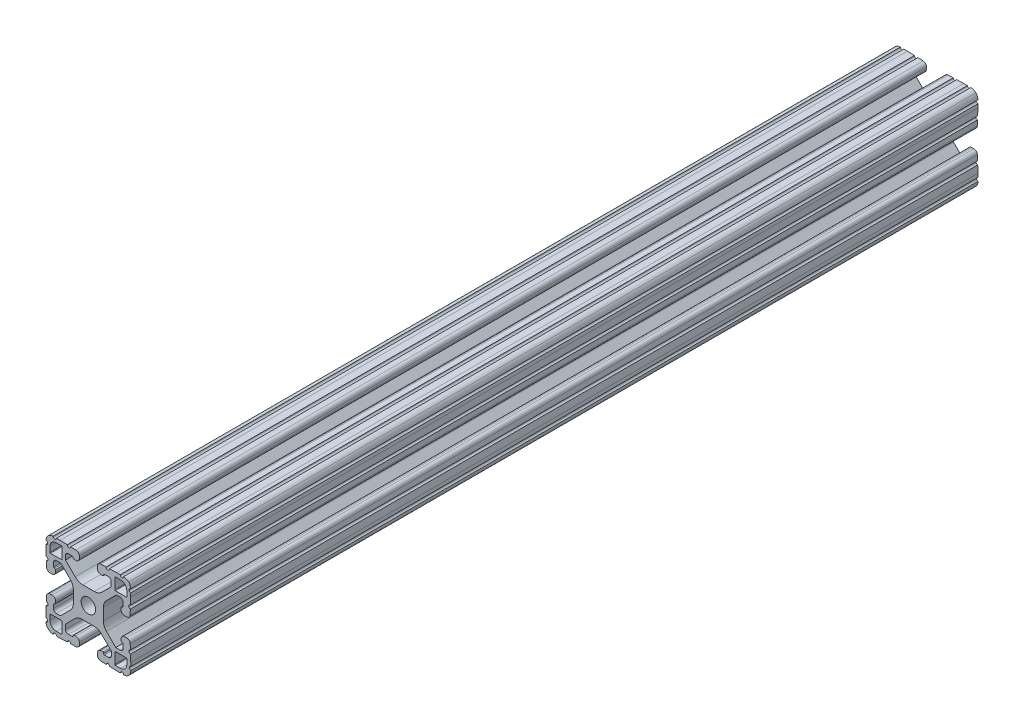
from build123d import *

# Parameters (mm, degrees)
SKETCH1_R           = 3.2639
BOSS_EXTRUDE1_DEPTH = 381


with BuildPart() as part:
    # Sketch1 → Boss-Extrude1 (new body)
    with BuildSketch(Plane(origin=(0, 0, -25.4), x_dir=(-1, 0, 0), z_dir=(0, 0, -1))):
        with BuildLine():
            Line((-88.043721549, 91.862643967), (-86.29674679, 91.923648859))
            ThreePointArc((-86.29674679, 91.923648859), (-85.370208675, 91.567983831), (-84.982425017, 90.654422489))
            Line((-84.982425017, 90.654422489), (-84.982425017, 88.800173916))
            Line((-84.982425017, 88.800173916), (-89.306565884, 84.476033049))
            ThreePointArc((-89.306565884, 84.476033049), (-90.866149908, 83.406077005), (-92.719610366, 83.029523439))
            Line((-92.719610366, 83.029523439), (-97.961628589, 83.029523439))
            ThreePointArc((-97.961628589, 83.029523439), (-99.779298356, 83.391080435), (-101.320244378, 84.42070765))
            Line((-101.320244378, 84.42070765), (-105.516001761, 88.616465033))
            Line((-105.516001761, 88.616465033), (-105.516001761, 90.731330035))
            ThreePointArc((-105.516001761, 90.731330035), (-105.128218103, 91.644891377), (-104.201679988, 92.000556406))
            Line((-104.201679988, 92.000556406), (-102.454705229, 91.939551513))
            ThreePointArc((-102.454705229, 91.939551513), (-102.193933359, 91.823448504), (-102.087001761, 91.558783602))
            ThreePointArc((-102.087001761, 91.558783602), (-102.010859042, 91.249291513), (-101.726191901, 91.105946874))
            Line((-101.726191901, 91.105946874), (-100.929727576, 91.078102142))
            ThreePointArc((-100.929727576, 91.078102142), (-99.780779944, 91.519102656), (-99.299905511, 92.651940638))
            Line((-99.299905511, 92.651940638), (-99.299905511, 93.566848638))
            ThreePointArc((-99.299905511, 93.566848638), (-99.741889517, 94.660796975), (-100.819746715, 95.140689345))
            Line((-100.819746715, 95.140689345), (-103.211918901, 95.224224422))
            ThreePointArc((-103.211918901, 95.224224422), (-104.000045777, 94.489281495), (-104.734990687, 95.277406522))
            Line((-104.734990687, 95.277406522), (-107.935905676, 95.389166912))
            Line((-107.935905676, 95.389166912), (-109.561454876, 95.389166912))
            ThreePointArc((-109.561454876, 95.389166912), (-110.323454876, 94.627166912), (-111.085454876, 95.389166912))
            ThreePointArc((-111.085454876, 95.389166912), (-112.308767787, 95.144035599), (-113.343184761, 94.446493225))
            ThreePointArc((-113.343184761, 94.446493225), (-114.04072548, 93.412075135), (-114.285854836, 92.188761832))
            ThreePointArc((-114.285854836, 92.188761832), (-113.523853616, 91.426762441), (-114.285853616, 90.664761832))
            Line((-114.285853616, 90.664761832), (-114.285853616, 89.039212632))
            Line((-114.285853616, 89.039212632), (-114.174093219, 85.838297643))
            ThreePointArc((-114.174093219, 85.838297643), (-113.385968191, 85.103352735), (-114.120911115, 84.315225857))
            Line((-114.120911115, 84.315225857), (-114.037376031, 81.923053667))
            ThreePointArc((-114.037376031, 81.923053667), (-113.55748366, 80.845196472), (-112.463535325, 80.403212468))
            Line((-112.463535325, 80.403212468), (-111.548627325, 80.403212468))
            ThreePointArc((-111.548627325, 80.403212468), (-110.415788905, 80.884087354), (-109.974788872, 82.033035791))
            Line((-109.974788872, 82.033035791), (-110.002634241, 82.829500094))
            ThreePointArc((-110.002634241, 82.829500094), (-110.118742417, 83.090261917), (-110.383401914, 83.197188))
            ThreePointArc((-110.383401914, 83.197188), (-110.693757401, 83.272605688), (-110.837665276, 83.557735272))
            Line((-110.837665276, 83.557735272), (-110.898671566, 85.304709982))
            ThreePointArc((-110.898671566, 85.304709982), (-110.543006925, 86.231248747), (-109.62944523, 86.61903277))
            Line((-109.62944523, 86.61903277), (-107.807161806, 86.61903277))
            Line((-107.807161806, 86.61903277), (-103.364925613, 82.176810793))
            ThreePointArc((-103.364925613, 82.176810793), (-102.335294479, 80.635862907), (-101.973736029, 78.81818963))
            Line((-101.973736029, 78.81818963), (-101.973736029, 73.576034207))
            ThreePointArc((-101.973736029, 73.576034207), (-102.335293752, 71.758362684), (-103.364922926, 70.21741573))
            Line((-103.364922926, 70.21741573), (-107.560683666, 66.021661704))
            Line((-107.560683666, 66.021661704), (-109.652436558, 66.021661704))
            ThreePointArc((-109.652436558, 66.021661704), (-110.565998503, 66.409445617), (-110.921663765, 67.335984343))
            Line((-110.921663765, 67.335984343), (-110.860658873, 69.082959102))
            ThreePointArc((-110.860658873, 69.082959102), (-110.744555864, 69.343730973), (-110.479890961, 69.45066257))
            ThreePointArc((-110.479890961, 69.45066257), (-110.173494703, 69.529390272), (-110.032185196, 69.812424443))
            Line((-110.032185196, 69.812424443), (-110.004340464, 70.608888768))
            ThreePointArc((-110.004340464, 70.608888768), (-110.445340978, 71.7578364), (-111.57817896, 72.238710833))
            Line((-111.57817896, 72.238710833), (-112.49308696, 72.238710833))
            ThreePointArc((-112.49308696, 72.238710833), (-113.587035297, 71.796726827), (-114.066927667, 70.718869629))
            Line((-114.066927667, 70.718869629), (-114.150462744, 68.326697443))
            ThreePointArc((-114.150462744, 68.326697443), (-113.415519817, 67.538570567), (-114.203644843, 66.803625657))
            Line((-114.203644843, 66.803625657), (-114.315405233, 63.602710668))
            Line((-114.315405233, 63.602710668), (-114.315405233, 61.962557497))
            ThreePointArc((-114.315405233, 61.962557497), (-113.701927281, 61.206106537), (-114.333208228, 60.464447842))
            ThreePointArc((-114.333208228, 60.464447842), (-114.113020459, 59.176546471), (-113.392816136, 58.086372941))
            ThreePointArc((-113.392816136, 58.086372941), (-112.358398046, 57.388832223), (-111.135084743, 57.143702867))
            ThreePointArc((-111.135084743, 57.143702867), (-110.373085352, 57.905704086), (-109.611084743, 57.143704086))
            Line((-109.611084743, 57.143704086), (-107.985535543, 57.143704086))
            Line((-107.985535543, 57.143704086), (-104.784620554, 57.255464483))
            ThreePointArc((-104.784620554, 57.255464483), (-104.049675645, 58.04358951), (-103.261548768, 57.308646586))
            Line((-103.261548768, 57.308646586), (-100.869376578, 57.39218167))
            ThreePointArc((-100.869376578, 57.39218167), (-99.791519383, 57.872074041), (-99.349535378, 58.966022376))
            Line((-99.349535378, 58.966022376), (-99.349535378, 59.880930376))
            ThreePointArc((-99.349535378, 59.880930376), (-99.830409811, 61.013768358), (-100.979357443, 61.454768873))
            Line((-100.979357443, 61.454768873), (-101.775821768, 61.42692414))
            ThreePointArc((-101.775821768, 61.42692414), (-102.036583684, 61.310816174), (-102.143509978, 61.046156762))
            ThreePointArc((-102.143509978, 61.046156762), (-102.222494916, 60.740061862), (-102.505377386, 60.598958297))
            Line((-102.505377386, 60.598958297), (-104.252352145, 60.537953405))
            ThreePointArc((-104.252352145, 60.537953405), (-105.17889026, 60.893618433), (-105.566673918, 61.807179775))
            Line((-105.566673918, 61.807179775), (-105.566673918, 63.629462758))
            Line((-105.566673918, 63.629462758), (-101.131142468, 68.064994208))
            ThreePointArc((-101.131142468, 68.064994208), (-99.590196446, 69.094621422), (-97.772526678, 69.456178419))
            Line((-97.772526678, 69.456178419), (-92.530356056, 69.456178419))
            ThreePointArc((-92.530356056, 69.456178419), (-90.712686289, 69.094621422), (-89.171740267, 68.064994208))
            Line((-89.171740267, 68.064994208), (-84.975982884, 63.869236825))
            Line((-84.975982884, 63.869236825), (-84.975982884, 61.781050107))
            ThreePointArc((-84.975982884, 61.781050107), (-85.363766542, 60.867488765), (-86.290304657, 60.511823736))
            Line((-86.290304657, 60.511823736), (-88.037279416, 60.572828629))
            ThreePointArc((-88.037279416, 60.572828629), (-88.298051286, 60.688931638), (-88.404982884, 60.95359654))
            ThreePointArc((-88.404982884, 60.95359654), (-88.466593694, 61.278962759), (-88.759626911, 61.433204782))
            Line((-88.759626911, 61.433204782), (-89.556091237, 61.461049514))
            ThreePointArc((-89.556091237, 61.461049514), (-90.705038868, 61.020049), (-91.185913301, 59.887211018))
            Line((-91.185913301, 59.887211018), (-91.185913301, 58.972303018))
            ThreePointArc((-91.185913301, 58.972303018), (-90.743929295, 57.878354681), (-89.666072098, 57.398462311))
            Line((-89.666072098, 57.398462311), (-87.273899911, 57.314927234))
            ThreePointArc((-87.273899911, 57.314927234), (-86.485773036, 58.049870161), (-85.750828126, 57.261745135))
            Line((-85.750828126, 57.261745135), (-82.549913136, 57.149984745))
            Line((-82.549913136, 57.149984745), (-80.924363936, 57.149984745))
            ThreePointArc((-80.924363936, 57.149984745), (-80.162363936, 57.911984745), (-79.400363936, 57.149984745))
            ThreePointArc((-79.400363936, 57.149984745), (-78.177051025, 57.395116058), (-77.142634052, 58.092658432))
            ThreePointArc((-77.142634052, 58.092658432), (-76.445094372, 59.127074031), (-76.199963977, 60.350384428))
            ThreePointArc((-76.199963977, 60.350384428), (-76.961961268, 61.112385783), (-76.199961268, 61.874384428))
            Line((-76.199961268, 61.874384428), (-76.199961268, 63.499933628))
            Line((-76.199961268, 63.499933628), (-76.311721666, 66.700848617))
            ThreePointArc((-76.311721666, 66.700848617), (-77.099846694, 67.435793525), (-76.364903769, 68.223920403))
            Line((-76.364903769, 68.223920403), (-76.448438853, 70.616092593))
            ThreePointArc((-76.448438853, 70.616092593), (-76.928331225, 71.693949788), (-78.02227956, 72.135933792))
            Line((-78.02227956, 72.135933792), (-78.93718756, 72.135933792))
            ThreePointArc((-78.93718756, 72.135933792), (-80.07002598, 71.655058906), (-80.511026012, 70.506110469))
            Line((-80.511026012, 70.506110469), (-80.483180643, 69.709646166))
            ThreePointArc((-80.483180643, 69.709646166), (-80.367072468, 69.448884343), (-80.102412971, 69.34195826))
            ThreePointArc((-80.102412971, 69.34195826), (-79.796317908, 69.262973649), (-79.655214052, 68.980091239))
            Line((-79.655214052, 68.980091239), (-79.594207761, 67.233116529))
            ThreePointArc((-79.594207761, 67.233116529), (-79.949872402, 66.306577764), (-80.863434097, 65.918793741))
            Line((-80.863434097, 65.918793741), (-82.685717521, 65.918793741))
            Line((-82.685717521, 65.918793741), (-87.121258001, 70.35431293))
            ThreePointArc((-87.121258001, 70.35431293), (-88.150863946, 71.895196205), (-88.512450271, 73.712794894))
            Line((-88.512450271, 73.712794894), (-88.512606864, 78.954950317))
            ThreePointArc((-88.512606864, 78.954950317), (-88.151076291, 80.772698182), (-87.121419968, 82.313710679))
            Line((-87.121419968, 82.313710679), (-82.925659228, 86.509464706))
            Line((-82.925659228, 86.509464706), (-80.837473527, 86.509464706))
            ThreePointArc((-80.837473527, 86.509464706), (-79.923911584, 86.121680793), (-79.568246321, 85.195142068))
            Line((-79.568246321, 85.195142068), (-79.629251214, 83.448167309))
            ThreePointArc((-79.629251214, 83.448167309), (-79.745354223, 83.187395438), (-80.010019125, 83.080463841))
            ThreePointArc((-80.010019125, 83.080463841), (-80.335385344, 83.018853031), (-80.489627367, 82.725819813))
            Line((-80.489627367, 82.725819813), (-80.5174721, 81.929355488))
            ThreePointArc((-80.5174721, 81.929355488), (-80.076471586, 80.780407856), (-78.943633603, 80.299533423))
            Line((-78.943633603, 80.299533423), (-78.028725603, 80.299533423))
            ThreePointArc((-78.028725603, 80.299533423), (-76.934777267, 80.741517429), (-76.454884897, 81.819374627))
            Line((-76.454884897, 81.819374627), (-76.37134982, 84.211546813))
            ThreePointArc((-76.37134982, 84.211546813), (-77.106292747, 84.999673689), (-76.31816772, 85.734618599))
            Line((-76.31816772, 85.734618599), (-76.20640733, 88.935533588))
            Line((-76.20640733, 88.935533588), (-76.20640733, 90.561082788))
            ThreePointArc((-76.20640733, 90.561082788), (-76.96840733, 91.323083398), (-76.206406111, 92.085082788))
            ThreePointArc((-76.206406111, 92.085082788), (-76.451535467, 93.308396091), (-77.149076185, 94.342814181))
            ThreePointArc((-77.149076185, 94.342814181), (-78.183493159, 95.040356555), (-79.40680607, 95.285487868))
            ThreePointArc((-79.40680607, 95.285487868), (-80.16880607, 94.523487868), (-80.93080607, 95.285487868))
            Line((-80.93080607, 95.285487868), (-82.55635527, 95.285487868))
            Line((-82.55635527, 95.285487868), (-85.757270259, 95.173727471))
            ThreePointArc((-85.757270259, 95.173727471), (-86.492215168, 94.385602444), (-87.280342045, 95.120545368))
            Line((-87.280342045, 95.120545368), (-89.672514235, 95.037010285))
            ThreePointArc((-89.672514235, 95.037010285), (-90.75037143, 94.557117913), (-91.192355435, 93.463169578))
            Line((-91.192355435, 93.463169578), (-91.192355435, 92.548261578))
            ThreePointArc((-91.192355435, 92.548261578), (-90.711481002, 91.415423596), (-89.56253337, 90.974423082))
            Line((-89.56253337, 90.974423082), (-88.766069045, 91.002267814))
            ThreePointArc((-88.766069045, 91.002267814), (-88.505307129, 91.11837578), (-88.398380835, 91.383035192))
            ThreePointArc((-88.398380835, 91.383035192), (-88.336765486, 91.708407548), (-88.043721549, 91.862643967))
        make_face()
        with Locations(Location((-95.25, 76.2, 0), (0, 0, 180))):  # turned: the seam where the file's is
            Circle(SKETCH1_R, mode=Mode.SUBTRACT)
        with BuildLine():
            Line((-83.357745393, 88.294108398), (-83.357745393, 93.170908398))
            ThreePointArc((-83.357745393, 93.170908398), (-83.283351492, 93.350512545), (-83.103748154, 93.424908398))
            Line((-83.103748154, 93.424908398), (-80.766975763, 93.424933798))
            ThreePointArc((-80.766975763, 93.424933798), (-78.791299784, 92.606600882), (-77.972945393, 90.630933798))
            Line((-77.972945393, 90.630933798), (-77.972945393, 88.294108398))
            ThreePointArc((-77.972945393, 88.294108398), (-78.047340271, 88.114503276), (-78.226945393, 88.040108398))
            Line((-78.226945393, 88.040108398), (-83.103745393, 88.040108398))
            ThreePointArc((-83.103745393, 88.040108398), (-83.283350516, 88.114503276), (-83.357745393, 88.294108398))
        make_face(mode=Mode.SUBTRACT)
        with BuildLine():
            Line((-83.357745393, 59.229091602), (-83.357745393, 64.105891602))
            ThreePointArc((-83.357745393, 64.105891602), (-83.283350516, 64.285496724), (-83.103745393, 64.359891602))
            Line((-83.103745393, 64.359891602), (-78.226945393, 64.359891602))
            ThreePointArc((-78.226945393, 64.359891602), (-78.047340271, 64.285496724), (-77.972945393, 64.105891602))
            Line((-77.972945393, 64.105891602), (-77.972945393, 61.769066202))
            ThreePointArc((-77.972945393, 61.769066202), (-78.791299784, 59.793399118), (-80.766975763, 58.975066202))
            Line((-80.766975763, 58.975066202), (-83.103748154, 58.975091602))
            ThreePointArc((-83.103748154, 58.975091602), (-83.283351492, 59.049487455), (-83.357745393, 59.229091602))
        make_face(mode=Mode.SUBTRACT)
        with BuildLine():
            Line((-107.142254607, 93.170908398), (-107.142254607, 88.294108398))
            ThreePointArc((-107.142254607, 88.294108398), (-107.216649484, 88.114503276), (-107.396254607, 88.040108398))
            Line((-107.396254607, 88.040108398), (-112.273054607, 88.040108398))
            ThreePointArc((-112.273054607, 88.040108398), (-112.452659729, 88.114503276), (-112.527054607, 88.294108398))
            Line((-112.527054607, 88.294108398), (-112.527054607, 90.630933798))
            ThreePointArc((-112.527054607, 90.630933798), (-111.708700216, 92.606600882), (-109.733024237, 93.424933798))
            Line((-109.733024237, 93.424933798), (-107.396251846, 93.424908398))
            ThreePointArc((-107.396251846, 93.424908398), (-107.216648508, 93.350512545), (-107.142254607, 93.170908398))
        make_face(mode=Mode.SUBTRACT)
        with BuildLine():
            Line((-107.142254607, 64.105891602), (-107.142254607, 59.229091602))
            ThreePointArc((-107.142254607, 59.229091602), (-107.216648508, 59.049487455), (-107.396251846, 58.975091602))
            Line((-107.396251846, 58.975091602), (-109.733024237, 58.975066202))
            ThreePointArc((-109.733024237, 58.975066202), (-111.708700216, 59.793399118), (-112.527054607, 61.769066202))
            Line((-112.527054607, 61.769066202), (-112.527054607, 64.105891602))
            ThreePointArc((-112.527054607, 64.105891602), (-112.452659729, 64.285496724), (-112.273054607, 64.359891602))
            Line((-112.273054607, 64.359891602), (-107.396254607, 64.359891602))
            ThreePointArc((-107.396254607, 64.359891602), (-107.216649484, 64.285496724), (-107.142254607, 64.105891602))
        make_face(mode=Mode.SUBTRACT)
    extrude(amount=-BOSS_EXTRUDE1_DEPTH)


solid = part.part
